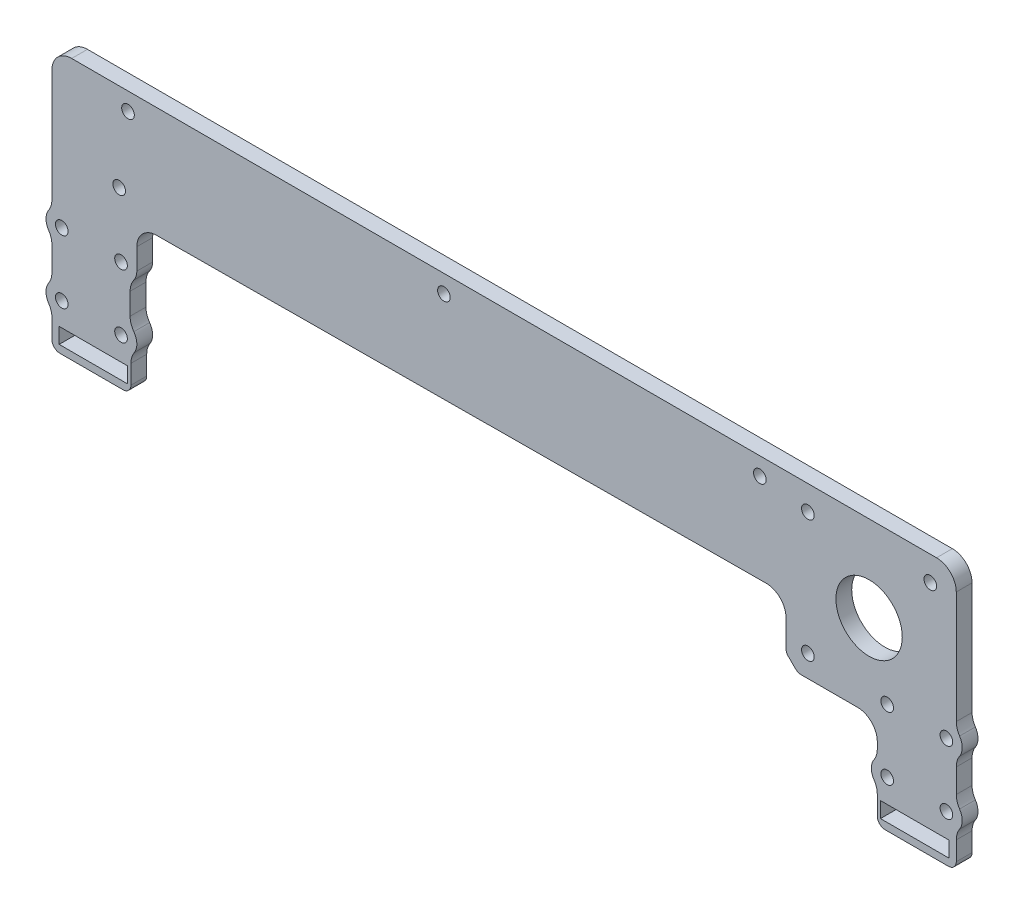
from build123d import *

# Parameters (mm, degrees)
RESSALTO_EXTRUS_O1_DEPTH = 4
M3_CLEARANCE_HOLE2_D     = 3.2
ESBO_O7_R                = 8.4
CORTE_EXTRUS_O1_DEPTH    = 10
M3_CLEARANCE_HOLE1_D     = 3.2
M3_CLEARANCE_HOLE3_D     = 3.2
FILETE1_R                = 5
M3_CLEARANCE_HOLE5_D     = 3.2
FILETE2_R                = 2
ESBO_O16_W               = 17.35833251
ESBO_O16_H               = 3.95
ESBO_O16_W_2             = 17.358332509
CUT_EXTRUDE1_DEPTH       = 4
FILLET2_R                = 5


with BuildPart() as part:
    # Esboço1 → Ressalto-extrusão1 (new body)
    with BuildSketch(Plane.XY):
        with BuildLine():
            Line((-95.048931647, 26.894793301), (-95.048931647, 18.252242094))
            Line((-95.048931647, 18.252242094), (-115.048931647, 18.252242094))
            Line((-115.048931647, 18.252242094), (-115.048931647, 26.894793301))
            ThreePointArc((-115.048931647, 26.894793301), (-116.548931647, 30.0172923), (-115.048931647, 33.139791299))
            Line((-115.048931647, 33.139791299), (-115.048931647, 42.894793301))
            ThreePointArc((-115.048931647, 42.894793301), (-116.548931647, 46.0172923), (-115.048931647, 49.139791299))
            Line((-115.048931647, 49.139791299), (-115.048931647, 84.40808297))
            Line((-115.048931647, 84.40808297), (113.954781763, 84.40808297))
            Line((113.954781763, 84.40808297), (113.954781763, 49.139791299))
            ThreePointArc((113.954781763, 49.139791299), (115.454781763, 46.0172923), (113.954781763, 42.894793301))
            Line((113.954781763, 42.894793301), (113.954781763, 33.139791299))
            ThreePointArc((113.954781763, 33.139791299), (115.454781763, 30.0172923), (113.954781763, 26.894793301))
            Line((113.954781763, 26.894793301), (113.954781763, 18.252242094))
            Line((113.954781763, 18.252242094), (93.954781763, 18.252242094))
            Line((93.954781763, 18.252242094), (93.954781763, 26.894793301))
            ThreePointArc((93.954781763, 26.894793301), (92.454781763, 30.0172923), (93.954781763, 33.139791299))
            Line((93.954781763, 33.139791299), (93.954781763, 41.612292304))
            Line((93.954781763, 41.612292304), (73.826556743, 41.612292304))
            Line((73.826556743, 41.612292304), (70.826556743, 44.612292304))
            Line((70.826556743, 44.612292304), (70.826556743, 57.286376167))
            Line((70.826556743, 57.286376167), (-93.548931647, 56.342842726))
            Line((-93.548931647, 56.342842726), (-93.548931647, 46.0172923))
            ThreePointArc((-93.548931647, 46.0172923), (-93.999283778, 44.173383409), (-95.248931647, 42.744678666))
            Line((-95.248931647, 42.744678666), (-95.248931647, 33.289905934))
            ThreePointArc((-95.248931647, 33.289905934), (-93.550886325, 30.142326699), (-95.048931647, 26.894793301))
        make_face()
    extrude(amount=RESSALTO_EXTRUS_O1_DEPTH)

    # M3 Clearance Hole2 (through all)
    with Locations(Plane.XY.offset(4)):
        with Locations((-112.548931647, 46.0172923), (-112.548931647, 30.0172923), (-97.548931647, 30.0172923), (-97.548931647, 46.0172923), (96.454781763, 30.0172923), (111.454781763, 30.0172923), (111.454781763, 46.06544156), (96.454781763, 46.0172923)):
            Hole(M3_CLEARANCE_HOLE2_D / 2)

    # Esboço7 → Corte-extrusão1 (cut)
    with BuildSketch(Plane(origin=(0, 0, 0), x_dir=(-1, 0, 0), z_dir=(0, 0, -1))):
        with Locations((-91.876556743, 62.662292304)):
            Circle(ESBO_O7_R)
    extrude(amount=-CORTE_EXTRUS_O1_DEPTH, mode=Mode.SUBTRACT)

    # M3 Clearance Hole1 (through all)
    with Locations(Plane(origin=(0, 0, 0), x_dir=(-1, 0, 0), z_dir=(0, 0, -1))):
        with Locations((98.016827352, 62.117292304)):
            Hole(M3_CLEARANCE_HOLE1_D / 2)

    # M3 Clearance Hole3 (through all)
    with Locations(Plane(origin=(0, 0, 0), x_dir=(-1, 0, 0), z_dir=(0, 0, -1))):
        with Locations((-76.376556743, 47.162292304), (-76.376556743, 78.162292304), (-107.376556743, 78.162292304)):
            Hole(M3_CLEARANCE_HOLE3_D / 2)

    # Filete1
    filete1_edges = [part.edges().sort_by_distance(p)[0] for p in [
        (113.954781763, 33.139791299, 2),
        (113.954781763, 26.894793301, 2),
        (93.954781763, 26.894793301, 2),
        (93.954781763, 33.139791299, 2),
        (93.954781763, 41.612292304, 2),
        (70.826556743, 57.286376167, 2),
        (-95.248931647, 42.744678666, 2),
        (-95.248931647, 33.289905934, 2),
        (-95.048931647, 26.894793301, 2),
        (-115.048931647, 26.894793301, 2),
        (-115.048931647, 33.139791299, 2),
        (-115.048931647, 42.894793301, 2),
        (-115.048931647, 49.139791299, 2),
        (-115.048931647, 84.40808297, 2),
        (113.954781763, 84.40808297, 2),
        (113.954781763, 49.139791299, 2),
        (113.954781763, 42.894793301, 2),
    ]]
    fillet(filete1_edges, radius=FILETE1_R)

    # M3 Clearance Hole5 (through all)
    with Locations(Plane.XY.offset(4)):
        with Locations((-95.783895796, 79.917292304), (64.216104204, 79.917292304), (-15.783895796, 79.917292304)):
            Hole(M3_CLEARANCE_HOLE5_D / 2)

    # Filete2
    filete2_edges = [part.edges().sort_by_distance(p)[0] for p in [
        (113.954781763, 18.252242094, 2),
        (93.954781763, 18.252242094, 2),
        (73.826556743, 41.612292304, 2),
        (70.826556743, 44.612292304, 2),
        (-95.048931647, 18.252242094, 2),
        (-115.048931647, 18.252242094, 2),
    ]]
    fillet(filete2_edges, radius=FILETE2_R)

    # Esboço16 → Cut-Extrude1 (cut)
    with BuildSketch(Plane.XY.offset(4)):
        with Locations((-104.531590398, 22.092946092)):
            Rectangle(ESBO_O16_W, ESBO_O16_H)
        with Locations((103.437440514, 22.092946092)):
            Rectangle(ESBO_O16_W_2, ESBO_O16_H)
    extrude(amount=-CUT_EXTRUDE1_DEPTH, mode=Mode.SUBTRACT)

    # Fillet2
    fillet2_edges = [part.edges().sort_by_distance(p)[0] for p in [
        (-93.548931647, 56.342842726, 2),
    ]]
    fillet(fillet2_edges, radius=FILLET2_R)


solid = part.part
